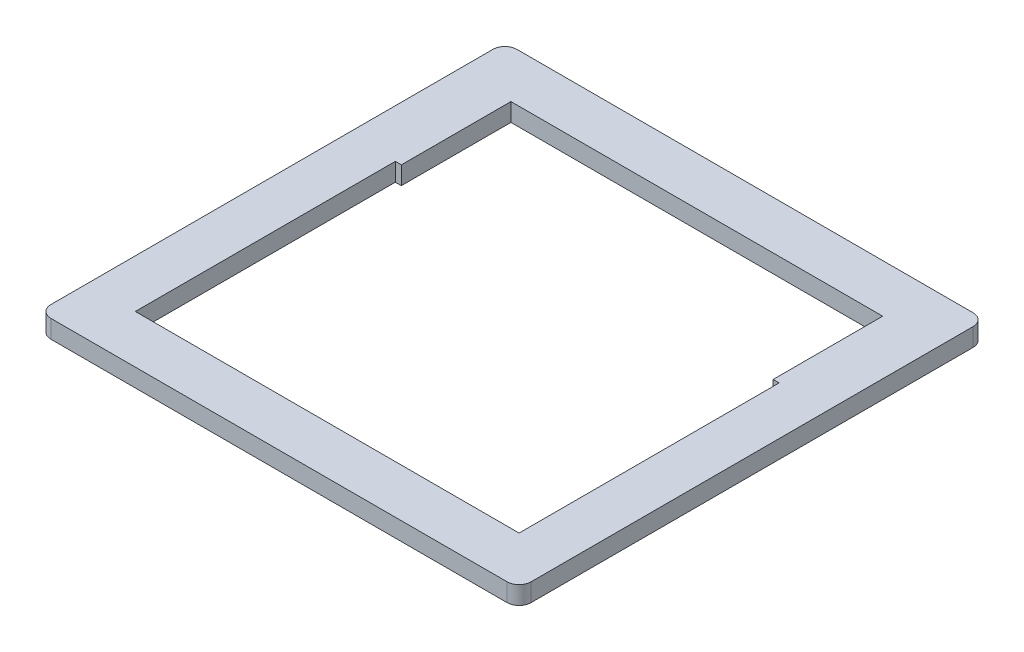
from build123d import *

# Parameters (mm, degrees)
EXTRUDE_1_DEPTH = 3


with BuildPart() as part:
    # 草图1 → 凸台-拉伸1 (new body)
    with BuildSketch(Plane(origin=(0, 0, 0), x_dir=(1, 0, 0), z_dir=(0, 1, 0))):
        with BuildLine():
            Line((-35.122340396, 46.844577244), (40.579802215, 46.844577244))
            ThreePointArc((40.579802215, 46.844577244), (41.994015777, 46.258790806), (42.579802215, 44.844577244))
            Line((42.579802215, 44.844577244), (42.579802215, -28.502662655))
            ThreePointArc((42.579802215, -28.502662655), (41.994015777, -29.916876218), (40.579802215, -30.502662655))
            Line((40.579802215, -30.502662655), (-35.122340396, -30.502662655))
            ThreePointArc((-35.122340396, -30.502662655), (-36.536553959, -29.916876218), (-37.122340396, -28.502662655))
            Line((-37.122340396, -28.502662655), (-37.122340396, 44.844577244))
            ThreePointArc((-37.122340396, 44.844577244), (-36.536553959, 46.258790806), (-35.122340396, 46.844577244))
        make_face()
        Polygon((-28.122340396, 20.655786491), (-28.122340396, 38.844577244), (33.579802215, 38.844577244), (33.579802215, 20.655786491), (34.579802215, 20.655786491), (34.579802215, -22.502662655), (-29.122340396, -22.502662655), (-29.122340396, 20.655786491), align=None, mode=Mode.SUBTRACT)
    extrude(amount=EXTRUDE_1_DEPTH)


solid = part.part
